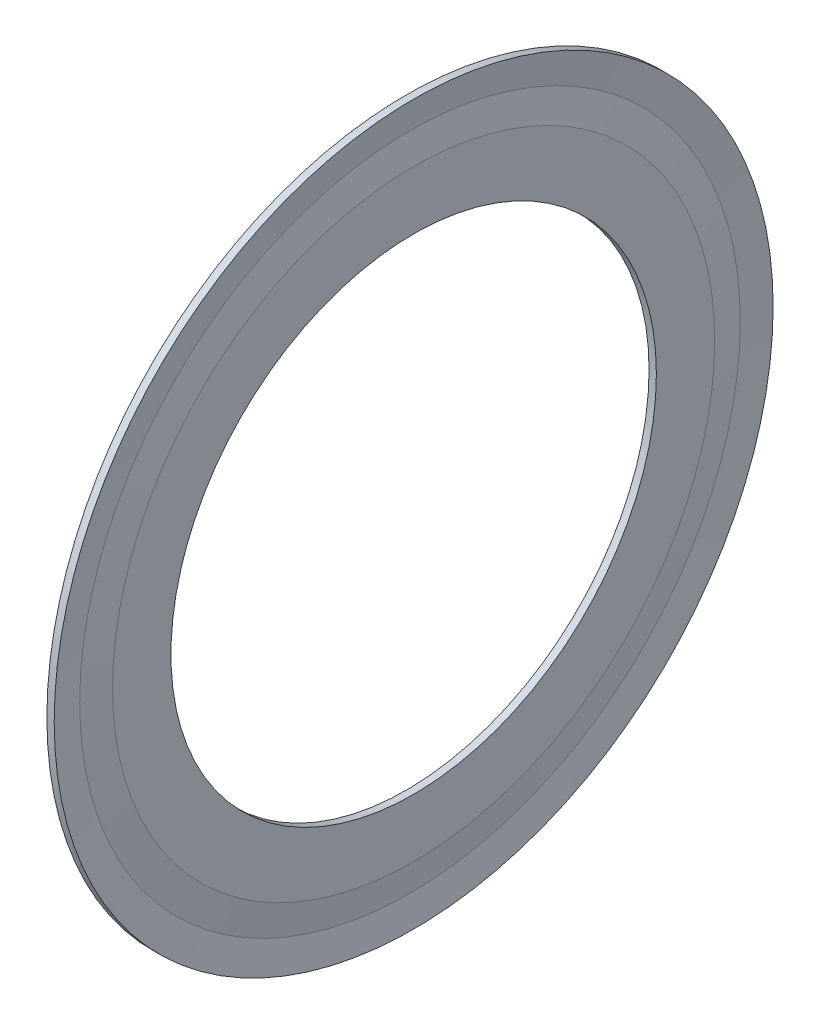
from build123d import *


with BuildPart() as part:
    # Sketch1 → Revolve1 (revolve)
    with BuildSketch(Plane.XY):
        Polygon((2.731748139, 3.039240506), (2.805651304, 2.45), (2.879554468, 2.45), (2.879554468, 3.039240506), (2.842602886, 3.333860759), (2.879554468, 3.628481013), (2.805651304, 3.628481013), (2.731748139, 3.31995724), align=None)
    revolve(axis=Axis((31.012658228, 0, 0), (-1, 0, 0)))


solid = part.part
